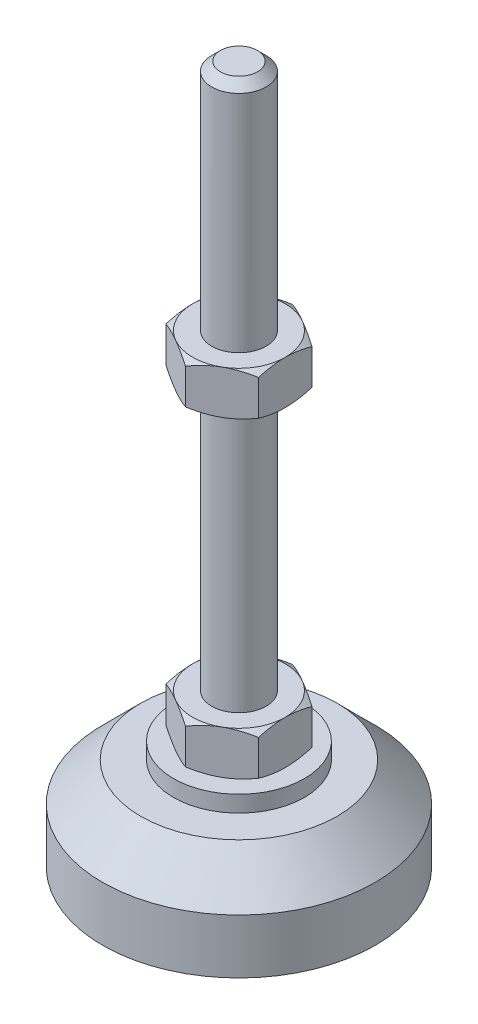
from build123d import *

# Parameters (mm, degrees)
EXTRUDE_1_DEPTH = 8
EXTRUDE_2_DEPTH = 8


with BuildPart() as part:
    # Эскиз1 → Повернуть1 (revolve)
    with BuildSketch(Plane.XY, mode=Mode.PRIVATE) as revolve_1_sk:
        Polygon((0, 0), (-25, 0), (-25, 10), (-18, 17), (-12, 17), (-12, 20), (-5, 20), (-5, 28), (-5, 126.4), (-3.4, 128), (0, 128), align=None)
    revolve(revolve_1_sk.sketch.rotate(Axis((0, 0, 0), (0, 1, 0)), 180), axis=Axis((0, 0, 0), (0, 1, 0)))  # turned: the seam where the file's is

    # Эскиз2 → Бобышка-Вытянуть1 (add)
    with BuildSketch(Plane(origin=(0, 20, 0), x_dir=(1, 0, 0), z_dir=(0, 1, 0))):
        Polygon((0, 9.814954576), (-8.5, 4.907477288), (-8.5, -4.907477288), (0, -9.814954576), (8.5, -4.907477288), (8.5, 4.907477288), align=None)
    extrude(amount=EXTRUDE_1_DEPTH)

    # Эскиз3 → Бобышка-Вытянуть2 (add)
    with BuildSketch(Plane(origin=(0, 77.2, 0), x_dir=(1, 0, 0), z_dir=(0, 1, 0))):
        Polygon((8.5, 4.907477288), (0, 9.814954576), (-8.5, 4.907477288), (-8.5, -4.907477288), (0, -9.814954576), (8.5, -4.907477288), align=None)
    extrude(amount=EXTRUDE_2_DEPTH)

    # Эскиз4 → Вырез-Повернуть2 (revolve, cut)
    with BuildSketch(Plane.XY, mode=Mode.PRIVATE) as cut_revolve_2_sk:
        Polygon((-15.42820323, 85.2), (-8.5, 85.2), (-15.42820323, 81.2), align=None)
        Polygon((-15.42820323, 77.2), (-15.42820323, 81.2), (-8.5, 77.2), align=None)
        Polygon((-15.42820323, 28), (-15.42820323, 24), (-8.5, 28), align=None)
        Polygon((-15.42820323, 24), (-15.42820323, 20), (-8.5, 20), align=None)
    revolve(cut_revolve_2_sk.sketch.rotate(Axis((0, 128, 0), (0, -1, 0)), 180), axis=Axis((0, 128, 0), (0, -1, 0)), mode=Mode.SUBTRACT)  # turned: the seam where the file's is


solid = part.part
